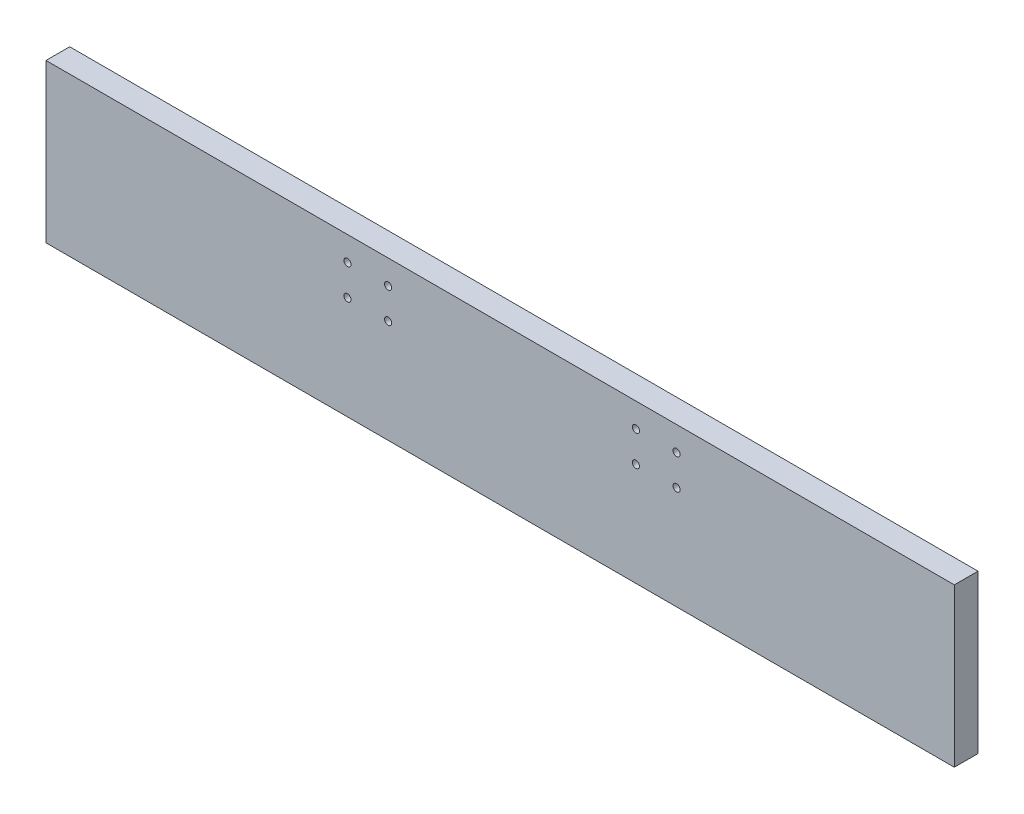
from build123d import *

# Parameters (mm, degrees)
SKETCH1_W           = 730.25
SKETCH1_H           = 127
BOSS_EXTRUDE1_DEPTH = 19.05
CUT_EXTRUDE1_REACH  = 21.05
SKETCH2_R           = 2.85115


with BuildPart() as part:
    # Sketch1 → Boss-Extrude1 (new body)
    with BuildSketch(Plane.XY):
        with Locations((365.125, 63.5)):
            Rectangle(SKETCH1_W, SKETCH1_H)
    extrude(amount=BOSS_EXTRUDE1_DEPTH)

    # Sketch2 → Cut-Extrude1 (cut, up to next)
    with BuildSketch(Plane.XY.offset(19.05), mode=Mode.PRIVATE) as cut_extrude1_sk1:
        with Locations((242.37315, 82.96275)):
            Circle(SKETCH2_R)
    cut_extrude1_tool1 = extrude(cut_extrude1_sk1.sketch, amount=-CUT_EXTRUDE1_REACH, mode=Mode.PRIVATE) & part.part
    add(cut_extrude1_tool1.solids().sort_by_distance((242.37315, 82.96275, 19.05))[0], mode=Mode.SUBTRACT)
    # Sketch2 → Cut-Extrude1 (cut, up to next)
    with BuildSketch(Plane.XY.offset(19.05), mode=Mode.PRIVATE) as cut_extrude1_sk2:
        with Locations((242.37315, 107.53725)):
            Circle(SKETCH2_R)
    cut_extrude1_tool2 = extrude(cut_extrude1_sk2.sketch, amount=-CUT_EXTRUDE1_REACH, mode=Mode.PRIVATE) & part.part
    add(cut_extrude1_tool2.solids().sort_by_distance((242.37315, 107.53725, 19.05))[0], mode=Mode.SUBTRACT)
    # Sketch2 → Cut-Extrude1 (cut, up to next)
    with BuildSketch(Plane.XY.offset(19.05), mode=Mode.PRIVATE) as cut_extrude1_sk3:
        with Locations((275.02485, 107.53725)):
            Circle(SKETCH2_R)
    cut_extrude1_tool3 = extrude(cut_extrude1_sk3.sketch, amount=-CUT_EXTRUDE1_REACH, mode=Mode.PRIVATE) & part.part
    add(cut_extrude1_tool3.solids().sort_by_distance((275.02485, 107.53725, 19.05))[0], mode=Mode.SUBTRACT)
    # Sketch2 → Cut-Extrude1 (cut, up to next)
    with BuildSketch(Plane.XY.offset(19.05), mode=Mode.PRIVATE) as cut_extrude1_sk4:
        with Locations((275.02485, 82.96275)):
            Circle(SKETCH2_R)
    cut_extrude1_tool4 = extrude(cut_extrude1_sk4.sketch, amount=-CUT_EXTRUDE1_REACH, mode=Mode.PRIVATE) & part.part
    add(cut_extrude1_tool4.solids().sort_by_distance((275.02485, 82.96275, 19.05))[0], mode=Mode.SUBTRACT)
    # Sketch2 → Cut-Extrude1 (cut, up to next)
    with BuildSketch(Plane.XY.offset(19.05), mode=Mode.PRIVATE) as cut_extrude1_sk5:
        with Locations((474.27515, 82.96275)):
            Circle(SKETCH2_R)
    cut_extrude1_tool5 = extrude(cut_extrude1_sk5.sketch, amount=-CUT_EXTRUDE1_REACH, mode=Mode.PRIVATE) & part.part
    add(cut_extrude1_tool5.solids().sort_by_distance((474.27515, 82.96275, 19.05))[0], mode=Mode.SUBTRACT)
    # Sketch2 → Cut-Extrude1 (cut, up to next)
    with BuildSketch(Plane.XY.offset(19.05), mode=Mode.PRIVATE) as cut_extrude1_sk6:
        with Locations((474.27515, 107.53725)):
            Circle(SKETCH2_R)
    cut_extrude1_tool6 = extrude(cut_extrude1_sk6.sketch, amount=-CUT_EXTRUDE1_REACH, mode=Mode.PRIVATE) & part.part
    add(cut_extrude1_tool6.solids().sort_by_distance((474.27515, 107.53725, 19.05))[0], mode=Mode.SUBTRACT)
    # Sketch2 → Cut-Extrude1 (cut, up to next)
    with BuildSketch(Plane.XY.offset(19.05), mode=Mode.PRIVATE) as cut_extrude1_sk7:
        with Locations((506.92685, 107.53725)):
            Circle(SKETCH2_R)
    cut_extrude1_tool7 = extrude(cut_extrude1_sk7.sketch, amount=-CUT_EXTRUDE1_REACH, mode=Mode.PRIVATE) & part.part
    add(cut_extrude1_tool7.solids().sort_by_distance((506.92685, 107.53725, 19.05))[0], mode=Mode.SUBTRACT)
    # Sketch2 → Cut-Extrude1 (cut, up to next)
    with BuildSketch(Plane.XY.offset(19.05), mode=Mode.PRIVATE) as cut_extrude1_sk8:
        with Locations((506.92685, 82.96275)):
            Circle(SKETCH2_R)
    cut_extrude1_tool8 = extrude(cut_extrude1_sk8.sketch, amount=-CUT_EXTRUDE1_REACH, mode=Mode.PRIVATE) & part.part
    add(cut_extrude1_tool8.solids().sort_by_distance((506.92685, 82.96275, 19.05))[0], mode=Mode.SUBTRACT)


solid = part.part
